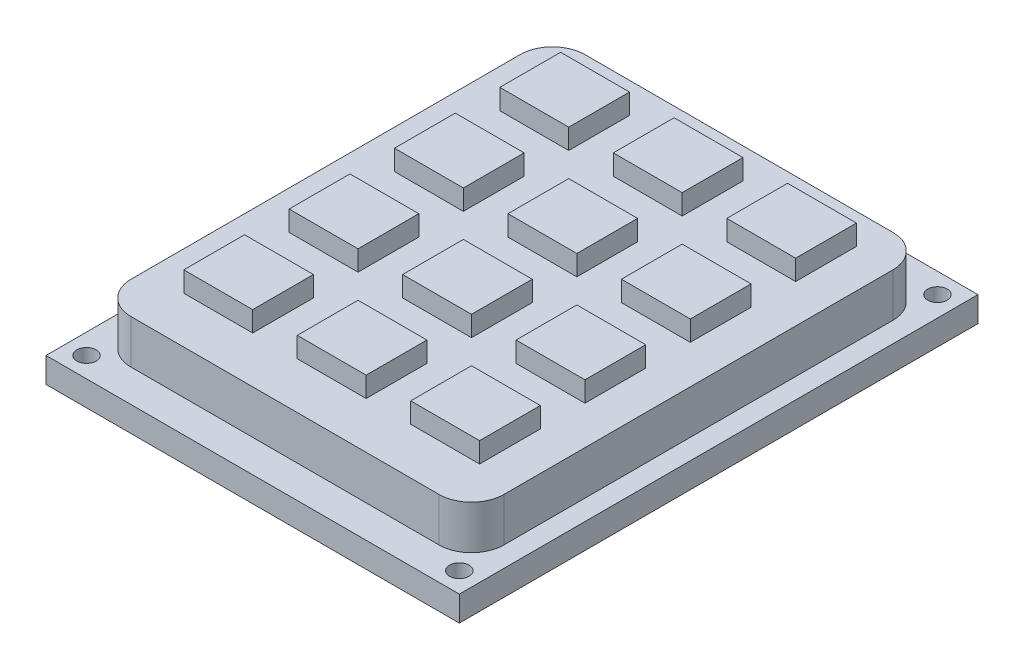
from build123d import *

# Parameters (mm, degrees)
SKETCH1_W           = 51
SKETCH1_H           = 64
BOSS_EXTRUDE1_DEPTH = 3.1
SKETCH2_R           = 1.2
CUT_EXTRUDE1_DEPTH  = 3.1
BOSS_EXTRUDE2_DEPTH = 5.4
SKETCH4_W           = 8.5
SKETCH4_H           = 7.5
BOSS_EXTRUDE4_DEPTH = 2.5


with BuildPart() as part:
    # Sketch1 → Boss-Extrude1 (new body)
    with BuildSketch(Plane(origin=(0, 0, 0), x_dir=(1, 0, 0), z_dir=(0, 1, 0))):
        Rectangle(SKETCH1_W, SKETCH1_H)
    extrude(amount=BOSS_EXTRUDE1_DEPTH)

    # Sketch2 → Cut-Extrude1 (cut)
    with BuildSketch(Plane(origin=(0, 3.1, 0), x_dir=(1, 0, 0), z_dir=(0, 1, 0))):
        with Locations((-23, 29.5)):
            Circle(SKETCH2_R)
        with Locations((23, 29.5)):
            Circle(SKETCH2_R)
        with Locations((23, -29.5)):
            Circle(SKETCH2_R)
        with Locations((-23, -29.5)):
            Circle(SKETCH2_R)
    extrude(amount=-CUT_EXTRUDE1_DEPTH, mode=Mode.SUBTRACT)

    # Sketch3 → Boss-Extrude2 (add)
    with BuildSketch(Plane(origin=(0, 3.1, 0), x_dir=(1, 0, 0), z_dir=(0, 1, 0))):
        with BuildLine():
            Line((-19, 28), (19, 28))
            ThreePointArc((19, 28), (21.828427125, 26.828427125), (23, 24))
            Line((23, 24), (23, -24))
            ThreePointArc((23, -24), (21.828427125, -26.828427125), (19, -28))
            Line((19, -28), (-19, -28))
            ThreePointArc((-19, -28), (-21.828427125, -26.828427125), (-23, -24))
            Line((-23, -24), (-23, 24))
            ThreePointArc((-23, 24), (-21.828427125, 26.828427125), (-19, 28))
        make_face()
    extrude(amount=BOSS_EXTRUDE2_DEPTH)

    # Sketch4 → Boss-Extrude4 (add)
    with BuildSketch(Plane(origin=(0, 8.5, 0), x_dir=(1, 0, 0), z_dir=(0, 1, 0))):
        with Locations((-14, 20.5)):
            Rectangle(SKETCH4_W, SKETCH4_H)
        with Locations((0, 20.5)):
            Rectangle(SKETCH4_W, SKETCH4_H)
        with Locations((14, 20.5)):
            Rectangle(SKETCH4_W, SKETCH4_H)
        Polygon((9.75, 11.25), (9.75, 3.75), (18.25, 3.75), (18.25, 11.25), (14, 11.25), align=None)
        with Locations((0, 7.5)):
            Rectangle(SKETCH4_W, SKETCH4_H)
        with Locations((-14, 7.5)):
            Rectangle(SKETCH4_W, SKETCH4_H)
        Polygon((-18.25, -1.75), (-18.25, -5.5), (-18.25, -9.25), (-9.75, -9.25), (-9.75, -1.75), align=None)
        with Locations((0, -5.5)):
            Rectangle(SKETCH4_W, SKETCH4_H)
        Polygon((18.25, -9.25), (18.25, -5.5), (18.25, -1.75), (9.75, -1.75), (9.75, -9.25), align=None)
        with Locations((14, -18.5)):
            Rectangle(SKETCH4_W, SKETCH4_H)
        with Locations((0, -18.5)):
            Rectangle(SKETCH4_W, SKETCH4_H)
        with Locations((-14, -18.5)):
            Rectangle(SKETCH4_W, SKETCH4_H)
    extrude(amount=BOSS_EXTRUDE4_DEPTH)


solid = part.part
